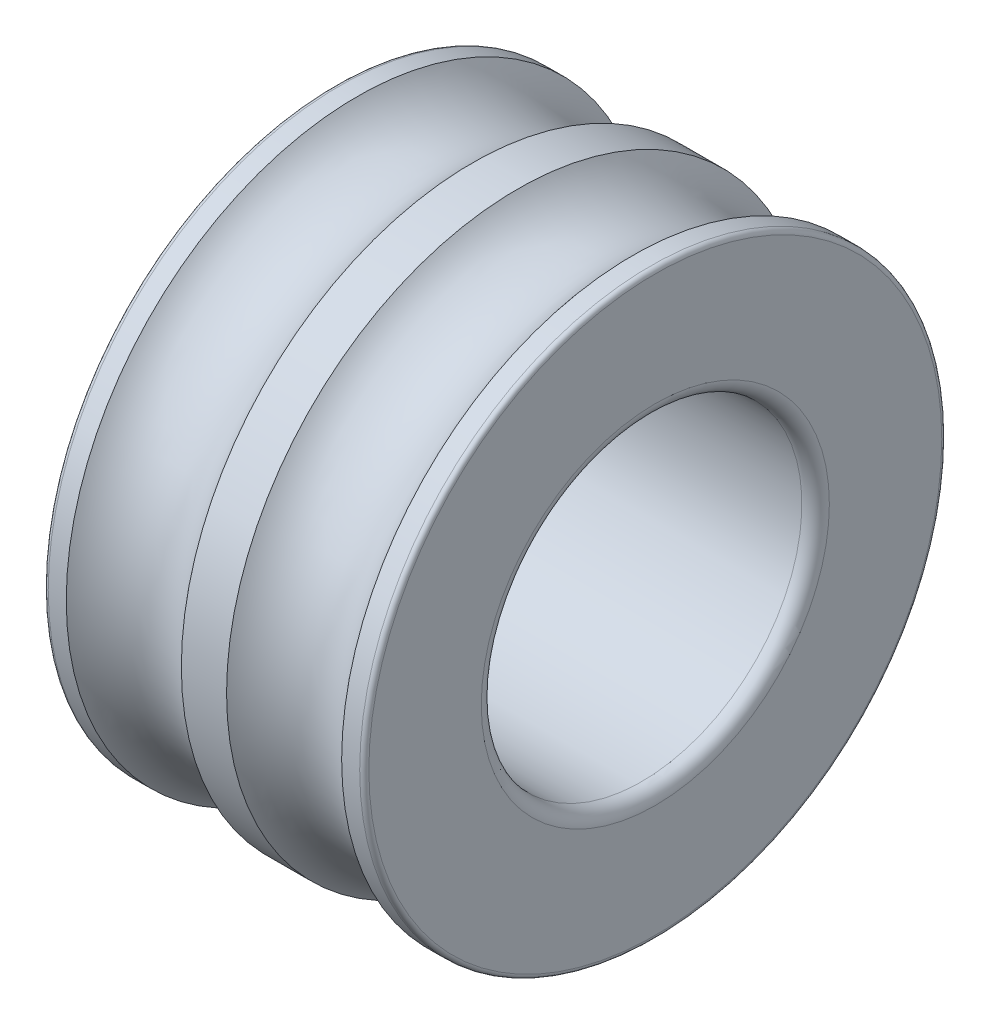
from build123d import *


with BuildPart() as part:
    # Sketch1 → Revolve1 (revolve)
    with BuildSketch(Plane.XY):
        with BuildLine():
            Line((0, 6.2545), (0, 3.8))
            ThreePointArc((0, 3.8), (0.087867966, 3.587867966), (0.3, 3.5))
            Line((0.3, 3.5), (6.7, 3.5))
            ThreePointArc((6.7, 3.5), (6.912132034, 3.587867966), (7, 3.8))
            Line((7, 3.8), (7, 6.2545))
            ThreePointArc((7, 6.2545), (6.970710678, 6.325210678), (6.9, 6.3545))
            Line((6.9, 6.3545), (6.506298531, 6.3545))
            ThreePointArc((6.506298531, 6.3545), (5.25, 5.7375), (3.993701469, 6.3545))
            Line((3.993701469, 6.3545), (3.006298531, 6.3545))
            ThreePointArc((3.006298531, 6.3545), (1.75, 5.7375), (0.493701469, 6.3545))
            Line((0.493701469, 6.3545), (0.1, 6.3545))
            ThreePointArc((0.1, 6.3545), (0.029289322, 6.325210678), (0, 6.2545))
        make_face()
    revolve(axis=Axis((50, 0, 0), (-1, 0, 0)))


solid = part.part
